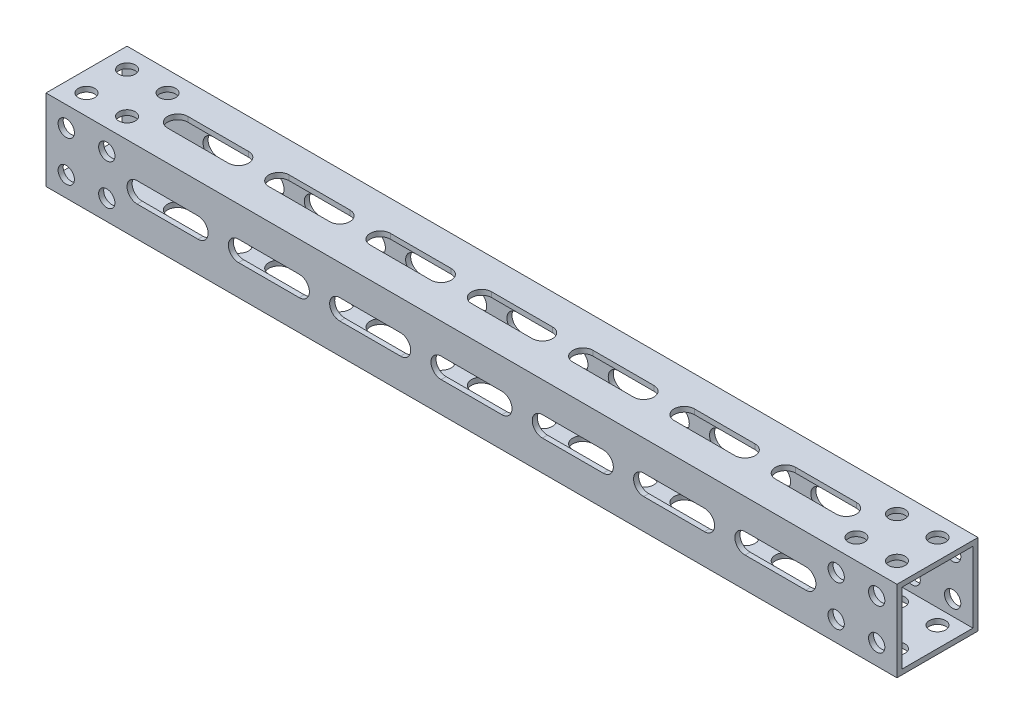
from build123d import *

# Parameters (mm, degrees)
SKETCH1_W              = 25.4
SKETCH1_H              = 25.4
SKETCH1_W_2            = 22.225
SKETCH1_H_2            = 22.225
EXTRUDE_THIN1_DEPTH    = 266.7
CUT_EXTRUDE1_DEPTH     = 26.4
CUT_EXTRUDE2_DEPTH     = 26.4
F_10_CLEARANCE_HOLE1_D = 5.1054
F_10_CLEARANCE_HOLE2_D = 5.1054


with BuildPart() as part:
    # Sketch1 → Extrude-Thin1 (new body)
    with BuildSketch(Plane(origin=(0, 0, 0), x_dir=(0, 0, -1), z_dir=(1, 0, 0))):
        Rectangle(SKETCH1_W, SKETCH1_H)
        Rectangle(SKETCH1_W_2, SKETCH1_H_2, mode=Mode.SUBTRACT)
    extrude(amount=EXTRUDE_THIN1_DEPTH)

    # Sketch2 → Cut-Extrude1 (cut, through all)
    with BuildSketch(Plane(origin=(0, 12.7, 0), x_dir=(1, 0, 0), z_dir=(0, 1, 0))):
        with BuildLine():
            Line((47.625, -3.175), (28.575, -3.175))
            ThreePointArc((28.575, -3.175), (25.4, 0), (28.575, 3.175))
            Line((28.575, 3.175), (47.625, 3.175))
            ThreePointArc((47.625, 3.175), (50.8, 0), (47.625, -3.175))
        make_face()
        with BuildLine():
            Line((79.375, -3.175), (60.325, -3.175))
            ThreePointArc((60.325, -3.175), (57.15, 0), (60.325, 3.175))
            Line((60.325, 3.175), (79.375, 3.175))
            ThreePointArc((79.375, 3.175), (82.55, 0), (79.375, -3.175))
        make_face()
        with BuildLine():
            Line((111.125, -3.175), (92.075, -3.175))
            ThreePointArc((92.075, -3.175), (88.9, 0), (92.075, 3.175))
            Line((92.075, 3.175), (111.125, 3.175))
            ThreePointArc((111.125, 3.175), (114.3, 0), (111.125, -3.175))
        make_face()
        with BuildLine():
            Line((142.875, -3.175), (123.825, -3.175))
            ThreePointArc((123.825, -3.175), (120.65, 0), (123.825, 3.175))
            Line((123.825, 3.175), (142.875, 3.175))
            ThreePointArc((142.875, 3.175), (146.05, 0), (142.875, -3.175))
        make_face()
        with BuildLine():
            Line((174.625, -3.175), (155.575, -3.175))
            ThreePointArc((155.575, -3.175), (152.4, 0), (155.575, 3.175))
            Line((155.575, 3.175), (174.625, 3.175))
            ThreePointArc((174.625, 3.175), (177.8, 0), (174.625, -3.175))
        make_face()
        with BuildLine():
            Line((206.375, -3.175), (187.325, -3.175))
            ThreePointArc((187.325, -3.175), (184.15, 0), (187.325, 3.175))
            Line((187.325, 3.175), (206.375, 3.175))
            ThreePointArc((206.375, 3.175), (209.55, 0), (206.375, -3.175))
        make_face()
        with BuildLine():
            Line((238.125, -3.175), (219.075, -3.175))
            ThreePointArc((219.075, -3.175), (215.9, 0), (219.075, 3.175))
            Line((219.075, 3.175), (238.125, 3.175))
            ThreePointArc((238.125, 3.175), (241.3, 0), (238.125, -3.175))
        make_face()
    extrude(amount=-CUT_EXTRUDE1_DEPTH, mode=Mode.SUBTRACT)

    # Sketch3 → Cut-Extrude2 (cut, through all)
    with BuildSketch(Plane(origin=(0, 0, -12.7), x_dir=(-1, 0, 0), z_dir=(0, 0, -1))):
        with BuildLine():
            Line((-28.575, -3.175), (-47.625, -3.175))
            ThreePointArc((-47.625, -3.175), (-50.8, 0), (-47.625, 3.175))
            Line((-47.625, 3.175), (-28.575, 3.175))
            ThreePointArc((-28.575, 3.175), (-25.4, 0), (-28.575, -3.175))
        make_face()
        with BuildLine():
            Line((-60.325, -3.175), (-79.375, -3.175))
            ThreePointArc((-79.375, -3.175), (-82.55, 0), (-79.375, 3.175))
            Line((-79.375, 3.175), (-60.325, 3.175))
            ThreePointArc((-60.325, 3.175), (-57.15, 0), (-60.325, -3.175))
        make_face()
        with BuildLine():
            Line((-92.075, -3.175), (-111.125, -3.175))
            ThreePointArc((-111.125, -3.175), (-114.3, 0), (-111.125, 3.175))
            Line((-111.125, 3.175), (-92.075, 3.175))
            ThreePointArc((-92.075, 3.175), (-88.9, 0), (-92.075, -3.175))
        make_face()
        with BuildLine():
            Line((-123.825, -3.175), (-142.875, -3.175))
            ThreePointArc((-142.875, -3.175), (-146.05, 0), (-142.875, 3.175))
            Line((-142.875, 3.175), (-123.825, 3.175))
            ThreePointArc((-123.825, 3.175), (-120.65, 0), (-123.825, -3.175))
        make_face()
        with BuildLine():
            Line((-155.575, -3.175), (-174.625, -3.175))
            ThreePointArc((-174.625, -3.175), (-177.8, 0), (-174.625, 3.175))
            Line((-174.625, 3.175), (-155.575, 3.175))
            ThreePointArc((-155.575, 3.175), (-152.4, 0), (-155.575, -3.175))
        make_face()
        with BuildLine():
            Line((-187.325, -3.175), (-206.375, -3.175))
            ThreePointArc((-206.375, -3.175), (-209.55, 0), (-206.375, 3.175))
            Line((-206.375, 3.175), (-187.325, 3.175))
            ThreePointArc((-187.325, 3.175), (-184.15, 0), (-187.325, -3.175))
        make_face()
        with BuildLine():
            Line((-219.075, -3.175), (-238.125, -3.175))
            ThreePointArc((-238.125, -3.175), (-241.3, 0), (-238.125, 3.175))
            Line((-238.125, 3.175), (-219.075, 3.175))
            ThreePointArc((-219.075, 3.175), (-215.9, 0), (-219.075, -3.175))
        make_face()
    extrude(amount=-CUT_EXTRUDE2_DEPTH, mode=Mode.SUBTRACT)

    # #10 Clearance Hole1 (through all)
    with Locations(Plane.XY.offset(12.7)):
        with Locations((6.35, 6.35), (19.05, 6.35), (19.05, -6.35), (6.35, -6.35), (260.35, -6.35), (247.65, -6.35), (247.65, 6.35), (260.35, 6.35)):
            Hole(F_10_CLEARANCE_HOLE1_D / 2)

    # #10 Clearance Hole2 (through all)
    with Locations(Plane(origin=(0, 12.7, 0), x_dir=(1, 0, 0), z_dir=(0, 1, 0))):
        with Locations((6.35, 6.35), (19.05, 6.35), (19.05, -6.35), (6.35, -6.35), (260.35, -6.35), (247.65, -6.35), (247.65, 6.35), (260.35, 6.35)):
            Hole(F_10_CLEARANCE_HOLE2_D / 2)


solid = part.part
